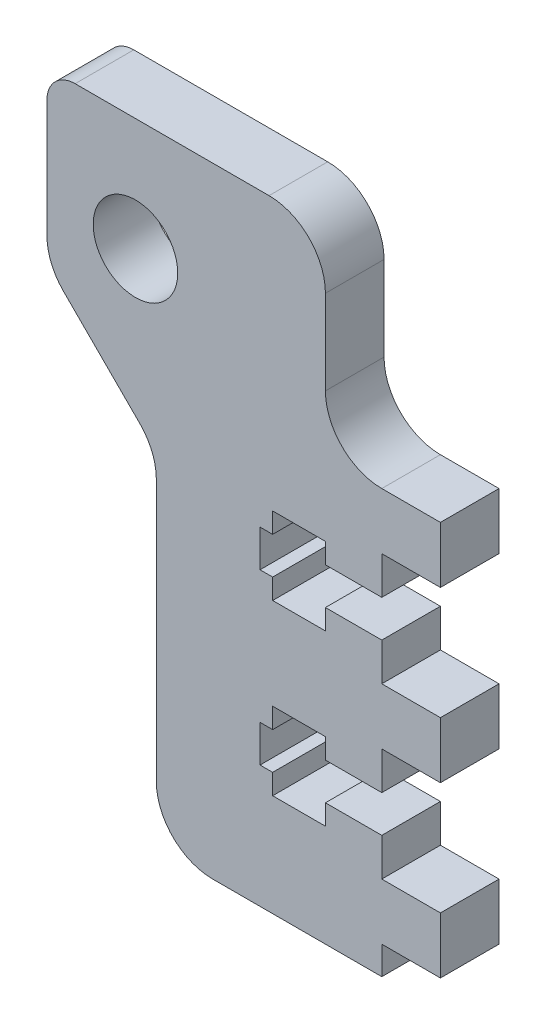
from build123d import *

# Parameters (mm, degrees)
SKETCH1_R           = 4.7625
BOSS_EXTRUDE1_DEPTH = 6.604
CUT_EXTRUDE1_DEPTH  = 7.604
SKETCH3_W           = 6.604
SKETCH3_H           = 6.35
BOSS_EXTRUDE2_DEPTH = 6.604
FILLET1_R           = 6.35
FILLET2_R           = 3.175


with BuildPart() as part:
    # Sketch1 → Boss-Extrude1 (new body)
    with BuildSketch(Plane.XY):
        Polygon((0, 0), (0, 47.625), (-6.35, 47.625), (-6.35, 69.85), (-37.719, 69.85), (-37.719, 50.8), (-25.4, 38.481), (-25.4, 0), align=None)
        with Locations((-27.7495, 57.15)):
            Circle(SKETCH1_R, mode=Mode.SUBTRACT)
    extrude(amount=BOSS_EXTRUDE1_DEPTH)

    # Sketch2 → Cut-Extrude1 (cut, through all)
    with BuildSketch(Plane.XY.offset(6.604)):
        Polygon((-12.2936, 37.0078), (-13.716, 37.0078), (-13.716, 32.8422), (-12.2936, 32.8422), (-12.2936, 30.5562), (-6.35, 30.5562), (-6.35, 32.8422), (0, 32.8422), (0, 37.0078), (-6.35, 37.0078), (-6.35, 39.2938), (-12.2936, 39.2938), align=None)
        Polygon((-12.2936, 20.2438), (-12.2936, 17.9578), (-13.716, 17.9578), (-13.716, 13.7922), (-12.2936, 13.7922), (-12.2936, 11.5062), (-6.35, 11.5062), (-6.35, 13.7922), (0, 13.7922), (0, 17.9578), (-6.35, 17.9578), (-6.35, 20.2438), align=None)
    extrude(amount=-CUT_EXTRUDE1_DEPTH, mode=Mode.SUBTRACT)

    # Sketch3 → Boss-Extrude2 (add)
    with BuildSketch(Plane.XY.offset(6.604)):
        with Locations((3.302, 44.45)):
            Rectangle(SKETCH3_W, SKETCH3_H)
        with Locations((3.302, 25.4)):
            Rectangle(SKETCH3_W, SKETCH3_H)
        with Locations((3.302, 6.35)):
            Rectangle(SKETCH3_W, SKETCH3_H)
    extrude(amount=-BOSS_EXTRUDE2_DEPTH)

    # Fillet1
    fillet1_edges = [part.edges().sort_by_distance(p)[0] for p in [
        (-25.4, 0, 3.302),
        (-25.4, 38.481, 3.302),
        (-37.719, 50.8, 3.302),
        (-6.35, 69.85, 3.302),
        (-6.35, 47.625, 3.302),
    ]]
    fillet(fillet1_edges, radius=FILLET1_R)

    # Fillet2
    fillet2_edges = [part.edges().sort_by_distance(p)[0] for p in [
        (-37.719, 69.85, 3.302),
    ]]
    fillet(fillet2_edges, radius=FILLET2_R)


solid = part.part
